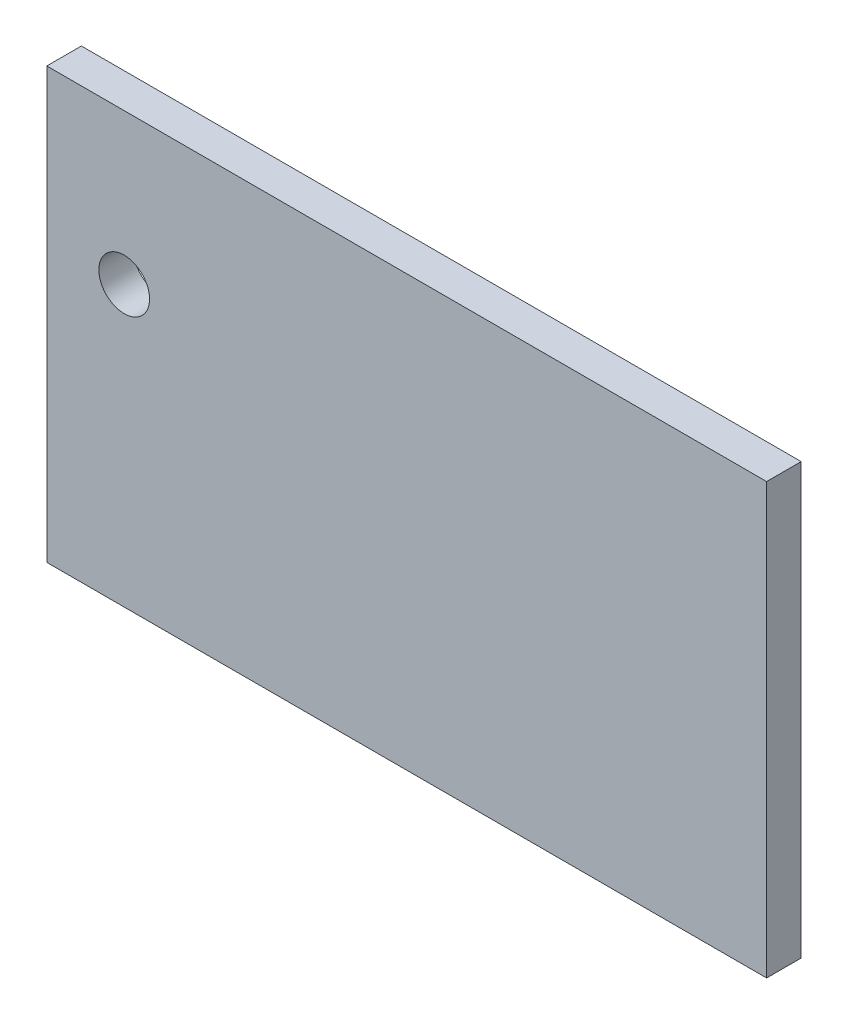
from build123d import *

# Parameters (mm, degrees)
SKETCH1_W           = 127.739076114
SKETCH1_H           = 76.296038139
BOSS_EXTRUDE1_DEPTH = 6.135
SKETCH2_R           = 4.5
CUT_EXTRUDE1_DEPTH  = 7.135


with BuildPart() as part:
    # Sketch1 → Boss-Extrude1 (new body)
    with BuildSketch(Plane.XY):
        with Locations((63.869538057, 38.14801907)):
            Rectangle(SKETCH1_W, SKETCH1_H)
    extrude(amount=BOSS_EXTRUDE1_DEPTH)

    # Sketch2 → Cut-Extrude1 (cut, through all)
    with BuildSketch(Plane.XY.offset(6.135)):
        with Locations((13.734764467, 49.590888918)):
            Circle(SKETCH2_R)
    extrude(amount=-CUT_EXTRUDE1_DEPTH, mode=Mode.SUBTRACT)


solid = part.part
